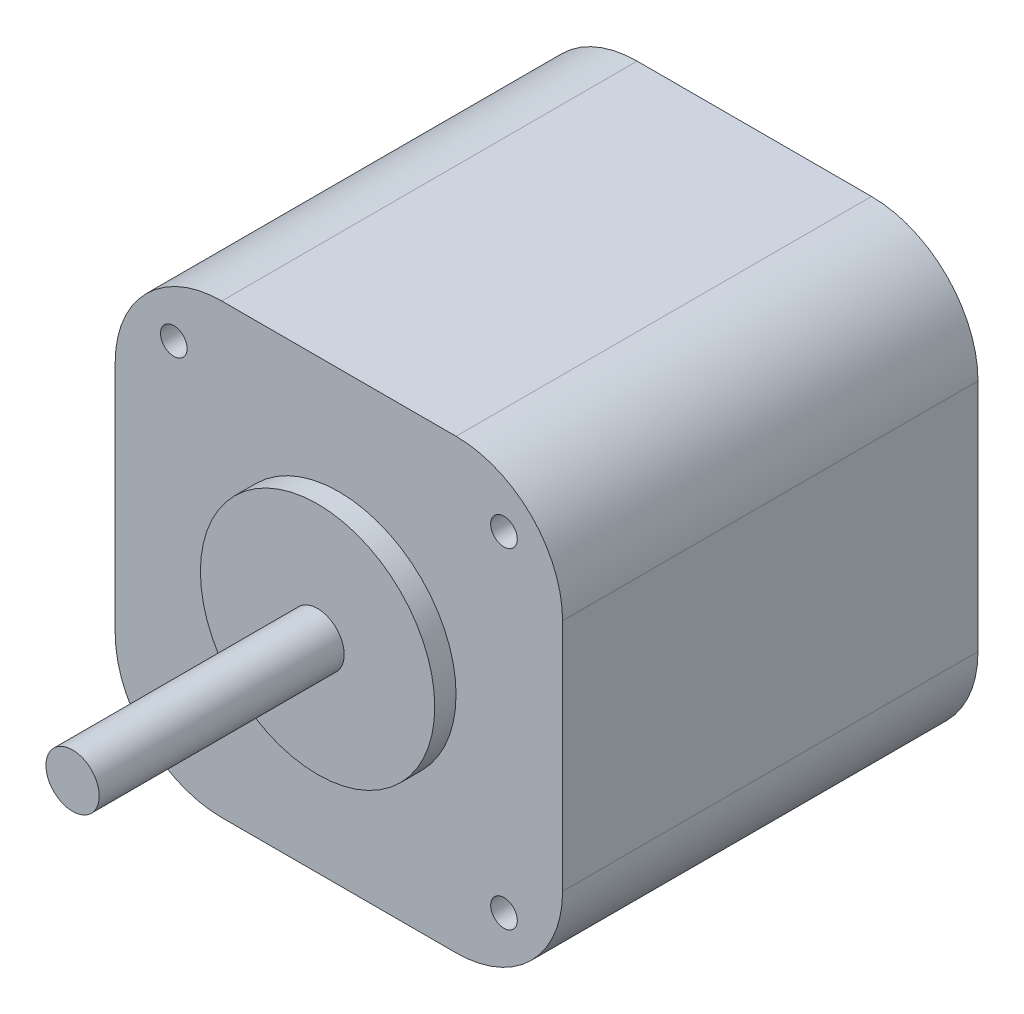
from build123d import *

# Parameters (mm, degrees)
SKETCH_1_W             = 42
SKETCH_1_H             = 42
EXTRUDE_1_DEPTH        = 39
FILLET_1_R             = 10
HOLE_WIZARD_M3_1_D     = 2.5
HOLE_WIZARD_M3_1_DEPTH = 7.5
HOLE_WIZARD_M3_1_TIP   = 0.751075774
SKETCH_4_R             = 11
EXTRUDE_2_DEPTH        = 2
SKETCH_5_R             = 2.5
EXTRUDE_3_DEPTH        = 23


with BuildPart() as part:
    # 草图1 → 凸台-拉伸1 (new body)
    with BuildSketch(Plane.XY):
        with Locations((21, 21)):
            Rectangle(SKETCH_1_W, SKETCH_1_H)
    extrude(amount=EXTRUDE_1_DEPTH)

    # 圆角1
    fillet_1_edges = [part.edges().sort_by_distance(p)[0] for p in [
        (0, 42, 19.5),
        (42, 42, 19.5),
        (42, 0, 19.5),
        (0, 0, 19.5),
    ]]
    fillet(fillet_1_edges, radius=FILLET_1_R)

    # M3 螺纹孔1
    with Locations(Plane.XY.offset(39)):
        with Locations((5.5, 36.5), (36.5, 36.5), (36.5, 5.5), (5.5, 5.5)):
            Hole(HOLE_WIZARD_M3_1_D / 2, depth=HOLE_WIZARD_M3_1_DEPTH)
            with Locations((0, 0, -(HOLE_WIZARD_M3_1_DEPTH + HOLE_WIZARD_M3_1_TIP / 2))):  # 118° drill point
                Cone(0, HOLE_WIZARD_M3_1_D / 2, HOLE_WIZARD_M3_1_TIP, mode=Mode.SUBTRACT)

    # 草图4 → 凸台-拉伸2 (add)
    with BuildSketch(Plane.XY.offset(39)):
        with Locations((21, 21)):
            Circle(SKETCH_4_R)
    extrude(amount=EXTRUDE_2_DEPTH)

    # 草图5 → 凸台-拉伸3 (add)
    with BuildSketch(Plane.XY.offset(41)):
        with Locations((21, 21)):
            Circle(SKETCH_5_R)
    extrude(amount=EXTRUDE_3_DEPTH)


solid = part.part
